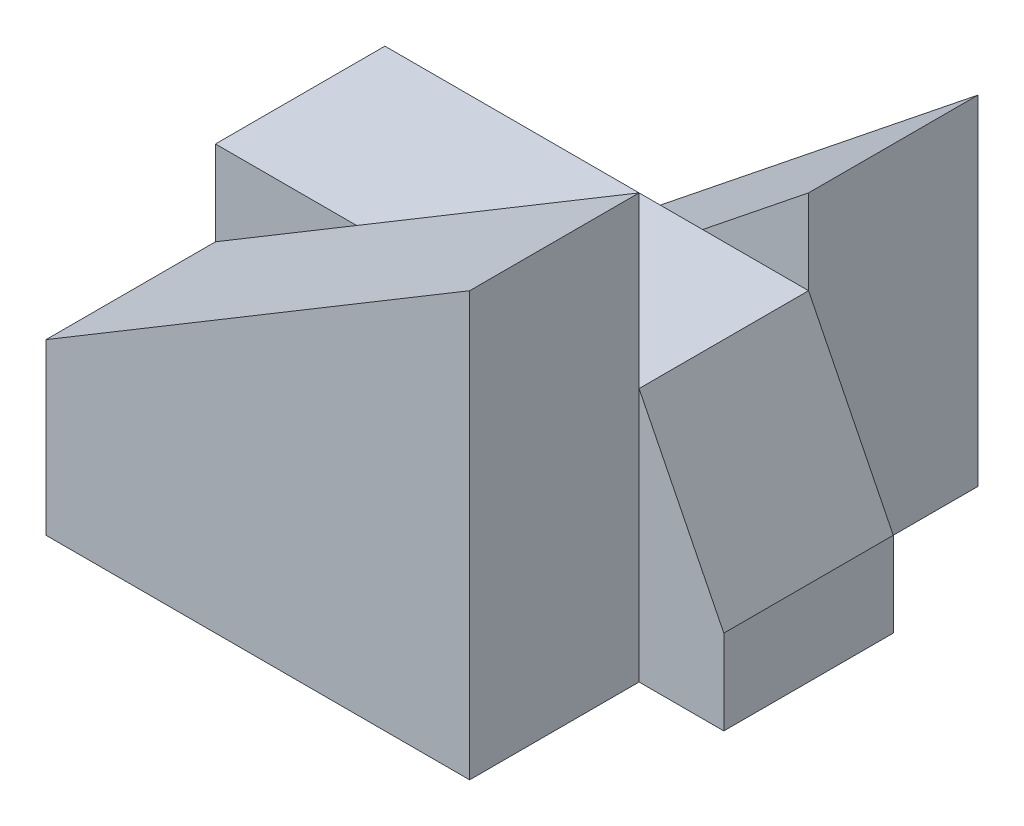
from build123d import *

# Parameters (mm, degrees)
BOSS_EXTRUDE9_DEPTH  = 10
BOSS_EXTRUDE10_DEPTH = 10
SKETCH8_W            = 25
SKETCH8_H            = 10
BOSS_EXTRUDE11_DEPTH = 10
BOSS_EXTRUDE12_DEPTH = 10


with BuildPart() as part:
    # Sketch1 → Boss-Extrude9 (new body)
    with BuildSketch(Plane.XY):
        Polygon((-25, 0), (0, 0), (0, 20), align=None)
    extrude(amount=BOSS_EXTRUDE9_DEPTH)

    # Sketch7 → Boss-Extrude10 (add)
    with BuildSketch(Plane.XY.offset(10)):
        Polygon((-25, 0), (-25, 15), (0, 15), (5, 5), (5, 0), align=None)
    extrude(amount=BOSS_EXTRUDE10_DEPTH)

    # Sketch8 → Boss-Extrude11 (add)
    with BuildSketch(Plane.XY.offset(20)):
        with Locations((-12.5, 5)):
            Rectangle(SKETCH8_W, SKETCH8_H)
    extrude(amount=BOSS_EXTRUDE11_DEPTH)

    # Sketch9 → Boss-Extrude12 (add)
    with BuildSketch(Plane.XY.offset(20)):
        Polygon((-25, 10), (0, 25), (0, 10), align=None)
    extrude(amount=BOSS_EXTRUDE12_DEPTH)


solid = part.part
